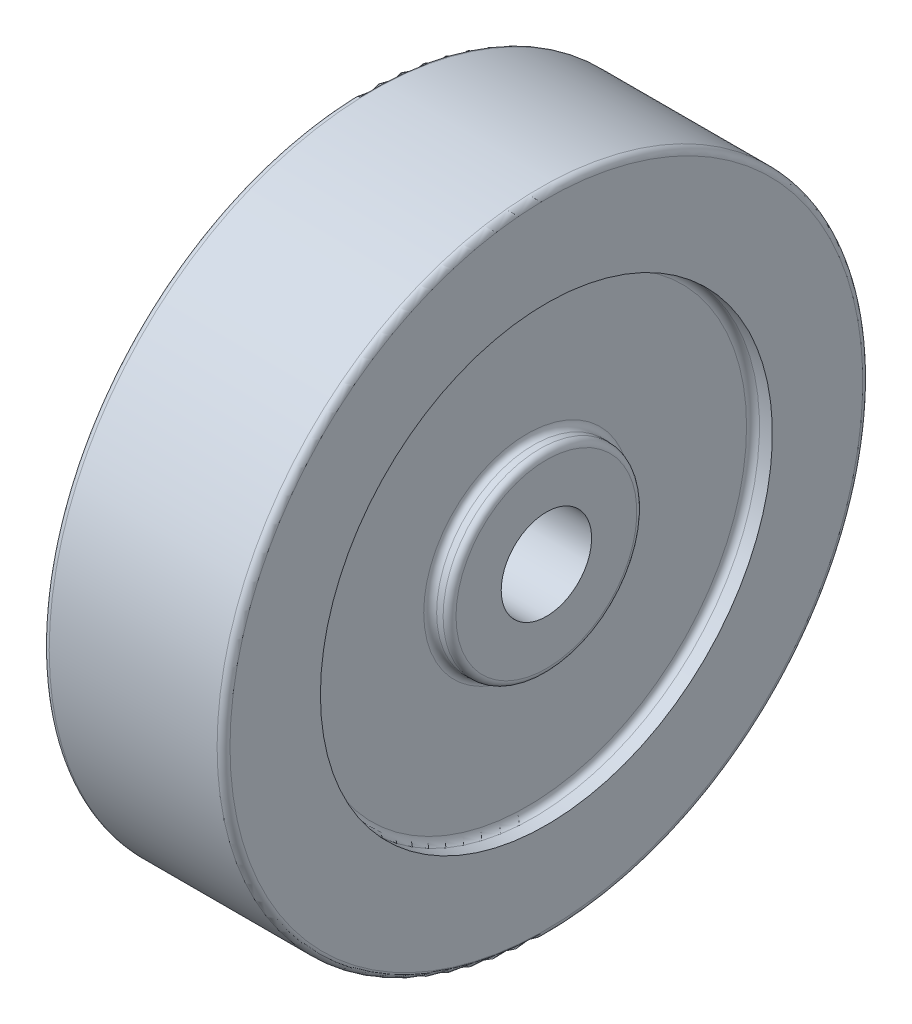
from build123d import *

# Parameters (mm, degrees)
FILLET1_R = 1


with BuildPart() as part:
    # Sketch1 → Revolve1 (revolve)
    with BuildSketch(Plane.XY):
        Polygon((-14, 7), (14, 7), (14, 15), (11, 15), (11, 35), (14, 35), (14, 50), (-14, 50), (-14, 35), (-11, 35), (-11, 15), (-14, 15), align=None)
    revolve(axis=Axis((0, 0, 0), (1, 0, 0)))

    # Fillet1
    fillet1_edges = [part.edges().sort_by_distance(p)[0] for p in [
        (-14, -50, 0),
        (14, -50, 0),
        (11, -35, 0),
        (11, -15, 0),
        (14, -15, 0),
        (-14, -15, 0),
        (-11, -15, 0),
        (-11, -35, 0),
    ]]
    fillet(fillet1_edges, radius=FILLET1_R)


solid = part.part
